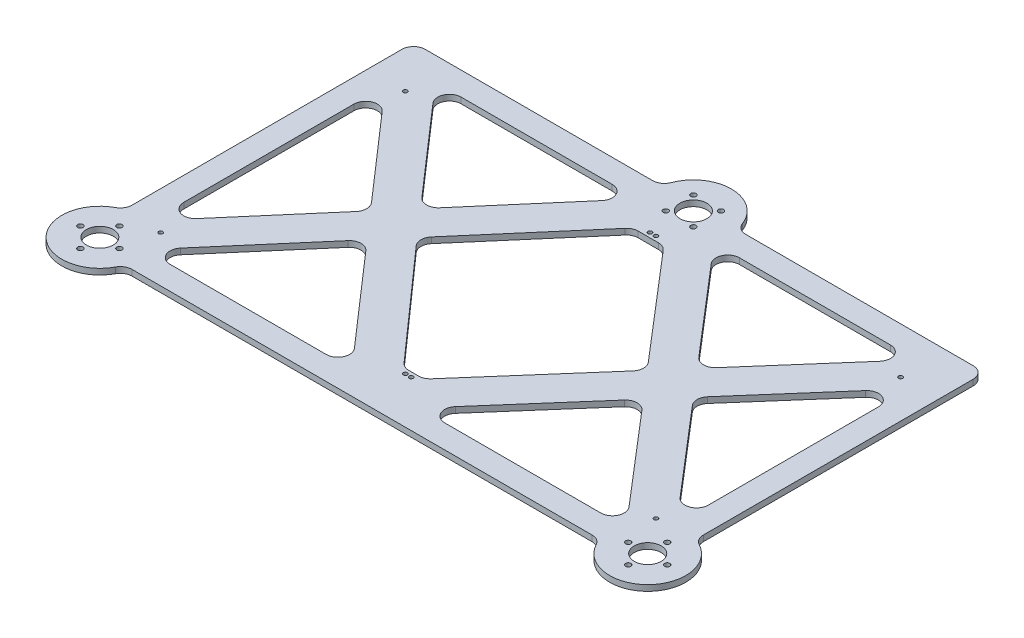
from build123d import *

# Parameters (mm, degrees)
ESQUISSE1_R        = 1.75
ESQUISSE1_R_2      = 11.5
ESQUISSE1_R_3      = 2.25
BOSS_EXTRU_1_DEPTH = 5


with BuildPart() as part:
    # Esquisse1 → Boss.-Extru.1 (new body)
    with BuildSketch(Plane(origin=(0, 0, 0), x_dir=(1, 0, 0), z_dir=(0, 1, 0))):
        with BuildLine():
            Line((-196.5, -144), (196.5, -144))
            ThreePointArc((196.5, -144), (201.644957554, -145.425070743), (205.323529412, -149.294117647))
            ThreePointArc((205.323529412, -149.294117647), (256.980970389, -156.980970389), (249.294117647, -105.323529412))
            ThreePointArc((249.294117647, -105.323529412), (245.425070743, -101.644957554), (244, -96.5))
            Line((244, -96.5), (244, 134))
            ThreePointArc((244, 134), (241.071067812, 141.071067812), (234, 144))
            Line((234, 144), (39.764934301, 144))
            ThreePointArc((39.764934301, 144), (34.076969712, 145.775216792), (30.408479172, 150.470588235))
            ThreePointArc((30.408479172, 150.470588235), (0, 171.5), (-30.408479172, 150.470588235))
            ThreePointArc((-30.408479172, 150.470588235), (-34.076969712, 145.775216792), (-39.764934301, 144))
            Line((-39.764934301, 144), (-234, 144))
            ThreePointArc((-234, 144), (-241.071067812, 141.071067812), (-244, 134))
            Line((-244, 134), (-244, -96.5))
            ThreePointArc((-244, -96.5), (-245.425070743, -101.644957554), (-249.294117647, -105.323529412))
            ThreePointArc((-249.294117647, -105.323529412), (-256.980970389, -156.980970389), (-205.323529412, -149.294117647))
            ThreePointArc((-205.323529412, -149.294117647), (-201.644957554, -145.425070743), (-196.5, -144))
        make_face()
        with Locations(Location((-2.5, 104.5, 0), (0, 0, 270))):  # turned: the seam where the file's is
            Circle(ESQUISSE1_R, mode=Mode.SUBTRACT)
        with Locations(Location((-211.5, 104.5, 0), (0, 0, 270))):  # turned: the seam where the file's is
            Circle(ESQUISSE1_R, mode=Mode.SUBTRACT)
        with Locations(Location((211.5, 104.5, 0), (0, 0, 90))):  # turned: the seam where the file's is
            Circle(ESQUISSE1_R, mode=Mode.SUBTRACT)
        with Locations(Location((2.5, 104.5, 0), (0, 0, 270))):  # turned: the seam where the file's is
            Circle(ESQUISSE1_R, mode=Mode.SUBTRACT)
        with Locations(Location((2.5, -104.5, 0), (0, 0, 90))):  # turned: the seam where the file's is
            Circle(ESQUISSE1_R, mode=Mode.SUBTRACT)
        with Locations(Location((-2.5, -104.5, 0), (0, 0, 90))):  # turned: the seam where the file's is
            Circle(ESQUISSE1_R, mode=Mode.SUBTRACT)
        with Locations(Location((-211.5, -104.5, 0), (0, 0, 90))):  # turned: the seam where the file's is
            Circle(ESQUISSE1_R, mode=Mode.SUBTRACT)
        with Locations(Location((211.5, -104.5, 0), (0, 0, 270))):  # turned: the seam where the file's is
            Circle(ESQUISSE1_R, mode=Mode.SUBTRACT)
        with Locations(Location((0, 139, 0), (0, 0, 270))):  # turned: the seam where the file's is
            Circle(ESQUISSE1_R_2, mode=Mode.SUBTRACT)
        with Locations(Location((-234, -134, 0), (0, 0, 270))):  # turned: the seam where the file's is
            Circle(ESQUISSE1_R_2, mode=Mode.SUBTRACT)
        with Locations(Location((234, -134, 0), (0, 0, 270))):  # turned: the seam where the file's is
            Circle(ESQUISSE1_R_2, mode=Mode.SUBTRACT)
        with Locations(Location((-11.787470042, 127.212529958, 0), (0, 0, 270))):  # turned: the seam where the file's is
            Circle(ESQUISSE1_R_3, mode=Mode.SUBTRACT)
        with Locations(Location((-11.787470042, 150.787470042, 0), (0, 0, 270))):  # turned: the seam where the file's is
            Circle(ESQUISSE1_R_3, mode=Mode.SUBTRACT)
        with Locations(Location((11.787470042, 150.787470042, 0), (0, 0, 270))):  # turned: the seam where the file's is
            Circle(ESQUISSE1_R_3, mode=Mode.SUBTRACT)
        with Locations(Location((11.787470042, 127.212529958, 0), (0, 0, 270))):  # turned: the seam where the file's is
            Circle(ESQUISSE1_R_3, mode=Mode.SUBTRACT)
        with Locations(Location((-234, -117.33, 0), (0, 0, 270))):  # turned: the seam where the file's is
            Circle(ESQUISSE1_R_3, mode=Mode.SUBTRACT)
        with Locations(Location((-217.33, -134, 0), (0, 0, 270))):  # turned: the seam where the file's is
            Circle(ESQUISSE1_R_3, mode=Mode.SUBTRACT)
        with Locations(Location((-234, -150.67, 0), (0, 0, 270))):  # turned: the seam where the file's is
            Circle(ESQUISSE1_R_3, mode=Mode.SUBTRACT)
        with Locations(Location((-250.67, -134, 0), (0, 0, 270))):  # turned: the seam where the file's is
            Circle(ESQUISSE1_R_3, mode=Mode.SUBTRACT)
        with Locations(Location((234, -117.33, 0), (0, 0, 270))):  # turned: the seam where the file's is
            Circle(ESQUISSE1_R_3, mode=Mode.SUBTRACT)
        with Locations(Location((250.67, -134, 0), (0, 0, 270))):  # turned: the seam where the file's is
            Circle(ESQUISSE1_R_3, mode=Mode.SUBTRACT)
        with Locations(Location((234, -150.67, 0), (0, 0, 270))):  # turned: the seam where the file's is
            Circle(ESQUISSE1_R_3, mode=Mode.SUBTRACT)
        with Locations(Location((217.33, -134, 0), (0, 0, 270))):  # turned: the seam where the file's is
            Circle(ESQUISSE1_R_3, mode=Mode.SUBTRACT)
        with BuildLine():
            Line((-190.881530392, 107.422917163), (-125.788799552, 32.872268168))
            ThreePointArc((-125.788799552, 32.872268168), (-118.210341928, 29.449455568), (-110.663506177, 32.94143727))
            Line((-110.663506177, 32.94143727), (-46.762949895, 107.492086265))
            ThreePointArc((-46.762949895, 107.492086265), (-45.270386934, 118.178568095), (-54.355515919, 124))
            Line((-54.355515919, 124), (-183.34880304, 124))
            ThreePointArc((-183.34880304, 124), (-192.452945734, 118.13697786), (-190.881530392, 107.422917163))
        make_face(mode=Mode.SUBTRACT)
        with BuildLine():
            Line((54.355515919, 124), (183.34880304, 124))
            ThreePointArc((183.34880304, 124), (192.452945734, 118.13697786), (190.881530392, 107.422917163))
            Line((190.881530392, 107.422917163), (125.788799552, 32.872268168))
            ThreePointArc((125.788799552, 32.872268168), (118.210341928, 29.449455568), (110.663506177, 32.94143727))
            Line((110.663506177, 32.94143727), (46.762949895, 107.492086265))
            ThreePointArc((46.762949895, 107.492086265), (45.270386934, 118.178568095), (54.355515919, 124))
        make_face(mode=Mode.SUBTRACT)
        with BuildLine():
            Line((-183.930198367, -124), (-50.65119696, -124))
            ThreePointArc((-50.65119696, -124), (-41.547054266, -118.13697786), (-43.118469608, -107.422917163))
            Line((-43.118469608, -107.422917163), (-110.373862185, -30.395373528))
            ThreePointArc((-110.373862185, -30.395373528), (-117.95231981, -26.972560928), (-125.49915556, -30.46454263))
            Line((-125.49915556, -30.46454263), (-191.52276439, -107.492086265))
            ThreePointArc((-191.52276439, -107.492086265), (-193.015327352, -118.178568095), (-183.930198367, -124))
        make_face(mode=Mode.SUBTRACT)
        with BuildLine():
            Line((-206.407433976, -78.759811829), (-143.545283572, -5.420636357))
            ThreePointArc((-143.545283572, -5.420636357), (-141.137954159, 1.13300765), (-143.605122244, 7.664360214))
            Line((-143.605122244, 7.664360214), (-206.467272648, 79.660327344))
            ThreePointArc((-206.467272648, 79.660327344), (-217.512315937, 82.446130641), (-224, 73.083244507))
            Line((-224, 73.083244507), (-224, -72.251898095))
            ThreePointArc((-224, -72.251898095), (-217.469462477, -81.630748244), (-206.407433976, -78.759811829))
        make_face(mode=Mode.SUBTRACT)
        with BuildLine():
            Line((16.237050105, 97.007913735), (92.617378166, 7.897530997))
            ThreePointArc((92.617378166, 7.897530997), (95.024707579, 1.343886989), (92.557539494, -5.187465575))
            Line((92.557539494, -5.187465575), (12.325560242, -97.077082837))
            ThreePointArc((12.325560242, -97.077082837), (8.929810751, -99.604142694), (4.792832891, -100.5))
            Line((4.792832891, -100.5), (-3.508962205, -100.5))
            ThreePointArc((-3.508962205, -100.5), (-7.610068471, -99.620357855), (-10.989673554, -97.136185479))
            Line((-10.989673554, -97.136185479), (-92.505523491, -5.246568217))
            ThreePointArc((-92.505523491, -5.246568217), (-95.024450072, 1.304521568), (-92.617378166, 7.897530997))
            Line((-92.617378166, 7.897530997), (-16.237050105, 97.007913735))
            ThreePointArc((-16.237050105, 97.007913735), (-12.823052176, 99.585128985), (-8.644484081, 100.5))
            Line((-8.644484081, 100.5), (8.644484081, 100.5))
            ThreePointArc((8.644484081, 100.5), (12.823052176, 99.585128985), (16.237050105, 97.007913735))
        make_face(mode=Mode.SUBTRACT)
        with BuildLine():
            Line((224, 73.083244507), (224, -72.251898095))
            ThreePointArc((224, -72.251898095), (217.469462477, -81.630748244), (206.407433976, -78.759811829))
            Line((206.407433976, -78.759811829), (143.545283572, -5.420636357))
            ThreePointArc((143.545283572, -5.420636357), (141.137954159, 1.13300765), (143.605122244, 7.664360214))
            Line((143.605122244, 7.664360214), (206.467272648, 79.660327344))
            ThreePointArc((206.467272648, 79.660327344), (217.512315937, 82.446130641), (224, 73.083244507))
        make_face(mode=Mode.SUBTRACT)
        with BuildLine():
            Line((125.49915556, -30.46454263), (191.52276439, -107.492086265))
            ThreePointArc((191.52276439, -107.492086265), (193.015327352, -118.178568095), (183.930198367, -124))
            Line((183.930198367, -124), (50.65119696, -124))
            ThreePointArc((50.65119696, -124), (41.547054266, -118.13697786), (43.118469608, -107.422917163))
            Line((43.118469608, -107.422917163), (110.373862185, -30.395373528))
            ThreePointArc((110.373862185, -30.395373528), (117.95231981, -26.972560928), (125.49915556, -30.46454263))
        make_face(mode=Mode.SUBTRACT)
    extrude(amount=BOSS_EXTRU_1_DEPTH)


solid = part.part
